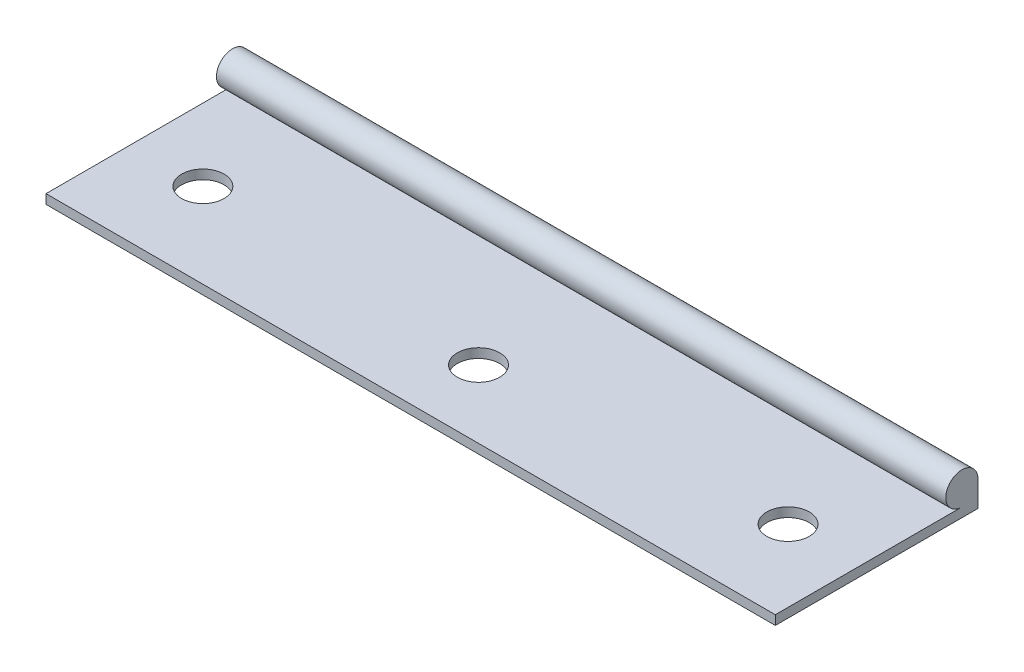
from build123d import *

# Parameters (mm, degrees)
SKETCH_1_R          = 1.9
EXTRUDE_1_DEPTH     = 86
SKETCH_2_R          = 2.5
CUT_EXTRUDE_1_DEPTH = 2.1


with BuildPart() as part:
    # 草图1 → 凸台-拉伸1 (new body)
    with BuildSketch(Plane(origin=(0, 0, 0), x_dir=(0, 0, -1), z_dir=(1, 0, 0))):
        with Locations((22, 3)):
            Circle(SKETCH_1_R)
        with BuildLine():
            Line((0, 1.1), (0, 0))
            Line((0, 0), (19, 0))
            Line((19, 0), (23.9, 0))
            Line((23.9, 0), (23.9, 3))
            ThreePointArc((23.9, 3), (23.343502884, 1.656497116), (22, 1.1))
            Line((22, 1.1), (19, 1.1))
            Line((19, 1.1), (0, 1.1))
        make_face()
    extrude(amount=EXTRUDE_1_DEPTH)

    # 草图2 → 切除-拉伸1 (cut, through all)
    with BuildSketch(Plane(origin=(0, 1.1, 0), x_dir=(1, 0, 0), z_dir=(0, 1, 0))):
        with Locations((8.5, 10)):
            Circle(SKETCH_2_R)
        with Locations((77.5, 10)):
            Circle(SKETCH_2_R)
        with Locations((43, 8)):
            Circle(SKETCH_2_R)
    extrude(amount=-CUT_EXTRUDE_1_DEPTH, mode=Mode.SUBTRACT)


solid = part.part
